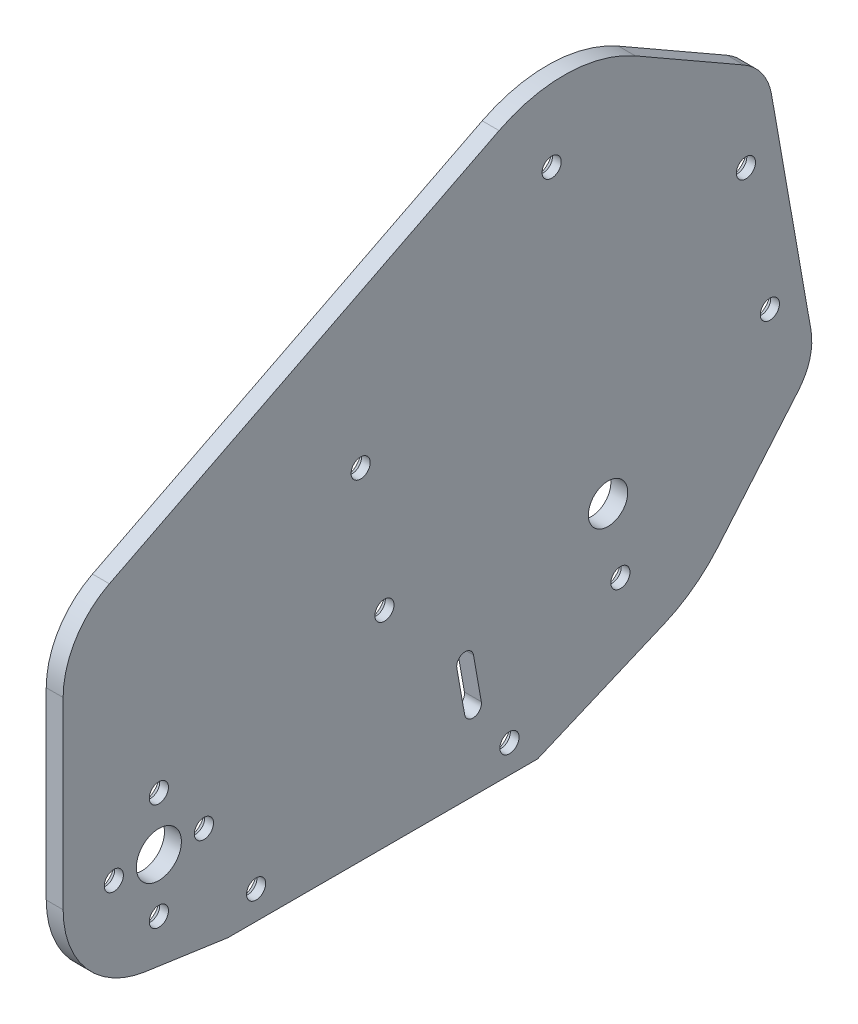
from build123d import *

# Parameters (mm, degrees)
BOSS_EXTRUDE1_DEPTH                            = 3
CSK_FOR_M3_FLAT_HEAD_MACHINE_SCREW1_AT_2_COUNT = 2
CSK_FOR_M3_FLAT_HEAD_MACHINE_SCREW1_AT_2_PITCH = 24.249778845
CSK_FOR_M3_FLAT_HEAD_MACHINE_SCREW1_AT_3_COUNT = 2
CSK_FOR_M3_FLAT_HEAD_MACHINE_SCREW1_AT_3_PITCH = 38.620366786
CSK_FOR_M3_FLAT_HEAD_MACHINE_SCREW1_AT_4_COUNT = 2
CSK_FOR_M3_FLAT_HEAD_MACHINE_SCREW1_AT_4_PITCH = 56.46506966
CSK_FOR_M3_FLAT_HEAD_MACHINE_SCREW1_AT_5_COUNT = 2
CSK_FOR_M3_FLAT_HEAD_MACHINE_SCREW1_AT_5_PITCH = 73.574936218
CSK_FOR_M3_FLAT_HEAD_MACHINE_SCREW1_AT_6_COUNT = 2
CSK_FOR_M3_FLAT_HEAD_MACHINE_SCREW1_AT_6_PITCH = 69.463901996
CSK_FOR_M3_FLAT_HEAD_MACHINE_SCREW1_AT_7_COUNT = 2
CSK_FOR_M3_FLAT_HEAD_MACHINE_SCREW1_AT_7_PITCH = 110.058179925
CSK_FOR_M3_FLAT_HEAD_MACHINE_SCREW1_AT_8_COUNT = 2
CSK_FOR_M3_FLAT_HEAD_MACHINE_SCREW1_AT_8_PITCH = 79.426938293
CSK_FOR_M3_FLAT_HEAD_MACHINE_SCREW1_AT_9_COUNT = 2
CSK_FOR_M3_FLAT_HEAD_MACHINE_SCREW1_AT_9_PITCH = 113.158637276
CSK_FOR_M3_FLAT_HEAD_MACHINE_SCREW1_AT_1_COUNT = 2
CSK_FOR_M3_FLAT_HEAD_MACHINE_SCREW1_AT_1_PITCH = 121.80851999
CSK_FOR_M3_FLAT_HEAD_MACHINE_SCREW1_2_COUNT    = 2
CSK_FOR_M3_FLAT_HEAD_MACHINE_SCREW1_2_PITCH    = 110.121224394
CSK_FOR_M3_FLAT_HEAD_MACHINE_SCREW1_3_COUNT    = 2
CSK_FOR_M3_FLAT_HEAD_MACHINE_SCREW1_3_PITCH    = 124.350346483
HOLE1_D                                        = 7
HOLE2_D                                        = 8
CUT_EXTRUDE1_DEPTH                             = 160.254847507


with BuildPart() as part:
    # Sketch2 → Boss-Extrude1 (new body)
    with BuildSketch(Plane.ZY.offset(20)):
        with BuildLine():
            Line((48.554021991, 101.961148745), (-20.652022209, 137.058847244))
            ThreePointArc((-20.652022209, 137.058847244), (-32.831883634, 139.808163597), (-44.856843921, 136.445412513))
            Line((-44.856843921, 136.445412513), (-64.147238229, 125.399811115))
            ThreePointArc((-64.147238229, 125.399811115), (-67.359474123, 122.47213667), (-69.026291478, 118.458228724))
            Line((-69.026291478, 118.458228724), (-76.03531425, 78.708085309))
            ThreePointArc((-76.03531425, 78.708085309), (-75.841855651, 74.366160521), (-73.824664919, 70.516397068))
            Line((-73.824664919, 70.516397068), (-59.475441909, 53.539223516))
            ThreePointArc((-59.475441909, 53.539223516), (-55.128189361, 49.472265428), (-49.95644752, 46.524072909))
            Line((-49.95644752, 46.524072909), (-27.5, 37))
            Line((-27.5, 37), (27.5, 37))
            Line((27.5, 37), (42.183846688, 39.106824497))
            ThreePointArc((42.183846688, 39.106824497), (52.615538646, 44.799981854), (56.769427994, 55.934497609))
            Line((56.769427994, 55.934497609), (56.769427994, 88.583208534))
            ThreePointArc((56.769427994, 88.583208534), (54.55162088, 96.432765529), (48.554021991, 101.961148745))
        make_face()
    extrude(amount=BOSS_EXTRUDE1_DEPTH)

    # Sketch4 → CSK for M3 Flat Head Machine Screw1 (revolve, cut)
    with BuildSketch(Plane(origin=(-23, 109.419717404, -64.490716019), x_dir=(0, 0, 1), z_dir=(0, 1, 0))):
        Polygon((0, 0), (0, 3), (1.7, 3), (1.7, 1.45), (3.15, 0), align=None)
    csk_for_m3_flat_head_machine_screw1 = revolve(axis=Axis((-29.35, 109.419717404, -64.490716019), (1, 0, 0)), mode=Mode.SUBTRACT)

    # CSK for M3 Flat Head Machine Screw1 at 2: CSK for M3 Flat Head Machine Screw1 ×2
    with Locations(*[Vector(1.2086661918503244e-15, -0.9845474999613615, -0.1751177327395287) * (i * CSK_FOR_M3_FLAT_HEAD_MACHINE_SCREW1_AT_2_PITCH) for i in range(1, CSK_FOR_M3_FLAT_HEAD_MACHINE_SCREW1_AT_2_COUNT)]):
        add(csk_for_m3_flat_head_machine_screw1, mode=Mode.SUBTRACT)

    # CSK for M3 Flat Head Machine Screw1 at 3: CSK for M3 Flat Head Machine Screw1 ×2
    with Locations(*[Vector(-6.2093706838556256e-15, 0.4493600398438155, 0.8933507455594162) * (i * CSK_FOR_M3_FLAT_HEAD_MACHINE_SCREW1_AT_3_PITCH) for i in range(1, CSK_FOR_M3_FLAT_HEAD_MACHINE_SCREW1_AT_3_COUNT)]):
        add(csk_for_m3_flat_head_machine_screw1, mode=Mode.SUBTRACT)

    # CSK for M3 Flat Head Machine Screw1 at 4: CSK for M3 Flat Head Machine Screw1 ×2
    with Locations(*[Vector(-2.752696921896813e-15, -0.9187544758485509, 0.39482934681739995) * (i * CSK_FOR_M3_FLAT_HEAD_MACHINE_SCREW1_AT_4_PITCH) for i in range(1, CSK_FOR_M3_FLAT_HEAD_MACHINE_SCREW1_AT_4_COUNT)]):
        add(csk_for_m3_flat_head_machine_screw1, mode=Mode.SUBTRACT)

    # CSK for M3 Flat Head Machine Screw1 at 5: CSK for M3 Flat Head Machine Screw1 ×2
    with Locations(*[Vector(-6.072091503896112e-15, -0.4885305965886132, 0.872546764475563) * (i * CSK_FOR_M3_FLAT_HEAD_MACHINE_SCREW1_AT_5_PITCH) for i in range(1, CSK_FOR_M3_FLAT_HEAD_MACHINE_SCREW1_AT_5_COUNT)]):
        add(csk_for_m3_flat_head_machine_screw1, mode=Mode.SUBTRACT)

    # CSK for M3 Flat Head Machine Screw1 at 6: CSK for M3 Flat Head Machine Screw1 ×2
    with Locations(*[Vector(-6.853396070159125e-15, -0.172037385949862, 0.985090421146982) * (i * CSK_FOR_M3_FLAT_HEAD_MACHINE_SCREW1_AT_6_PITCH) for i in range(1, CSK_FOR_M3_FLAT_HEAD_MACHINE_SCREW1_AT_6_COUNT)]):
        add(csk_for_m3_flat_head_machine_screw1, mode=Mode.SUBTRACT)

    # CSK for M3 Flat Head Machine Screw1 at 7: CSK for M3 Flat Head Machine Screw1 ×2
    with Locations(*[Vector(-5.503795198596271e-15, -0.6125825218052937, 0.790406638369559) * (i * CSK_FOR_M3_FLAT_HEAD_MACHINE_SCREW1_AT_7_PITCH) for i in range(1, CSK_FOR_M3_FLAT_HEAD_MACHINE_SCREW1_AT_7_COUNT)]):
        add(csk_for_m3_flat_head_machine_screw1, mode=Mode.SUBTRACT)

    # CSK for M3 Flat Head Machine Screw1 at 8: CSK for M3 Flat Head Machine Screw1 ×2
    with Locations(*[Vector(-3.678987335552319e-15, -0.8488268445511623, 0.528670963803874) * (i * CSK_FOR_M3_FLAT_HEAD_MACHINE_SCREW1_AT_8_PITCH) for i in range(1, CSK_FOR_M3_FLAT_HEAD_MACHINE_SCREW1_AT_8_COUNT)]):
        add(csk_for_m3_flat_head_machine_screw1, mode=Mode.SUBTRACT)

    # CSK for M3 Flat Head Machine Screw1 at 9: CSK for M3 Flat Head Machine Screw1 ×2
    with Locations(*[Vector(-6.412606110908794e-15, -0.38870404286920884, 0.9213626685823191) * (i * CSK_FOR_M3_FLAT_HEAD_MACHINE_SCREW1_AT_9_PITCH) for i in range(1, CSK_FOR_M3_FLAT_HEAD_MACHINE_SCREW1_AT_9_COUNT)]):
        add(csk_for_m3_flat_head_machine_screw1, mode=Mode.SUBTRACT)

    # CSK for M3 Flat Head Machine Screw1 at 1: CSK for M3 Flat Head Machine Screw1 ×2
    with Locations(*[Vector(-5.9572332785295035e-15, -0.5170838607967878, 0.855934741030815) * (i * CSK_FOR_M3_FLAT_HEAD_MACHINE_SCREW1_AT_1_PITCH) for i in range(1, CSK_FOR_M3_FLAT_HEAD_MACHINE_SCREW1_AT_1_COUNT)]):
        add(csk_for_m3_flat_head_machine_screw1, mode=Mode.SUBTRACT)

    # CSK for M3 Flat Head Machine Screw1  2: CSK for M3 Flat Head Machine Screw1 ×2
    with Locations(*[Vector(-6.089422911582908e-15, -0.48569401665402473, 0.8741288933483895) * (i * CSK_FOR_M3_FLAT_HEAD_MACHINE_SCREW1_2_PITCH) for i in range(1, CSK_FOR_M3_FLAT_HEAD_MACHINE_SCREW1_2_COUNT)]):
        add(csk_for_m3_flat_head_machine_screw1, mode=Mode.SUBTRACT)

    # CSK for M3 Flat Head Machine Screw1  3: CSK for M3 Flat Head Machine Screw1 ×2
    with Locations(*[Vector(-6.285442955682349e-15, -0.43011717544362077, 0.9027730697071117) * (i * CSK_FOR_M3_FLAT_HEAD_MACHINE_SCREW1_3_PITCH) for i in range(1, CSK_FOR_M3_FLAT_HEAD_MACHINE_SCREW1_3_COUNT)]):
        add(csk_for_m3_flat_head_machine_screw1, mode=Mode.SUBTRACT)

    # Hole1 (through all)
    with Locations(Plane.ZY.offset(23)):
        with Locations((-40, 70)):
            Hole(HOLE1_D / 2)

    # Hole2 (through all)
    with Locations(Plane.ZY.offset(23)):
        with Locations((39.769427994, 55.934497609)):
            Hole(HOLE2_D / 2)

    # Sketch10 → Cut-Extrude1 (cut, through all)
    with BuildSketch(Plane.ZY.offset(23)):
        with BuildLine():
            Line((-17.492124963, 50.799855174), (-16.102939542, 58.678317198))
            ThreePointArc((-16.102939542, 58.678317198), (-14.365255646, 59.895056561), (-13.148516283, 58.157372665))
            Line((-13.148516283, 58.157372665), (-14.537701704, 50.278910641))
            ThreePointArc((-14.537701704, 50.278910641), (-16.2753856, 49.062171278), (-17.492124963, 50.799855174))
        make_face()
    extrude(amount=-CUT_EXTRUDE1_DEPTH, mode=Mode.SUBTRACT)


solid = part.part
